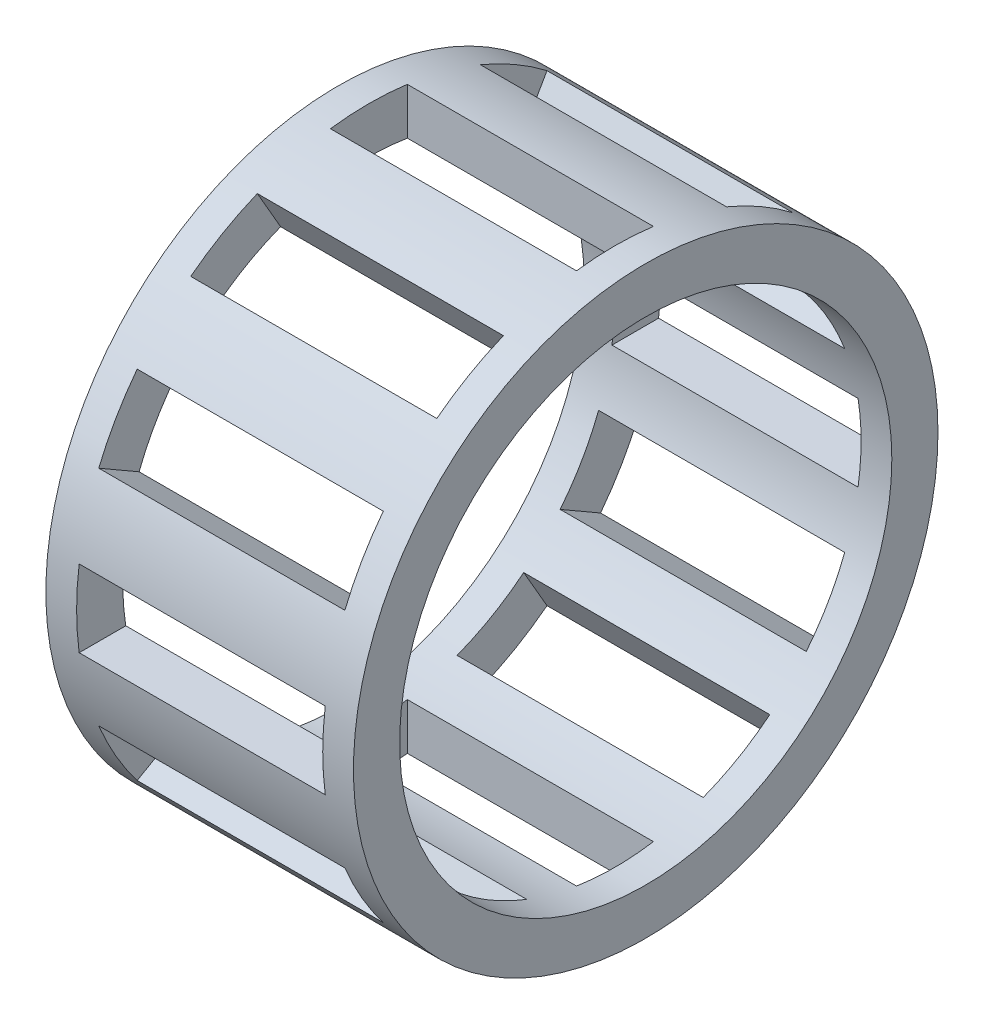
from build123d import *

# Parameters (mm, degrees)
ESQUISSE1_W                  = 10
ESQUISSE1_H                  = 1.5
ESQUISSE2_W                  = 8
ESQUISSE2_H                  = 2.5
ENL_V_MAT_EXTRU_1_DEPTH      = 15.335271187
R_P_TITION_CIRCULAIRE1_COUNT = 12


with BuildPart() as part:
    # Esquisse1 → Base-Révolution (revolve)
    with BuildSketch(Plane.XY):
        with Locations((0, 8.75)):
            Rectangle(ESQUISSE1_W, ESQUISSE1_H)
    revolve(axis=Axis((11.7, 0, 0), (-1, 0, 0)))

    # Esquisse2 → Enlèv. mat.-Extru.1 (cut, through all)
    with BuildSketch(Plane.XY):
        Rectangle(ESQUISSE2_W, ESQUISSE2_H)
    enl_v_mat_extru_1 = extrude(amount=-ENL_V_MAT_EXTRU_1_DEPTH, mode=Mode.SUBTRACT)

    # Répétition circulaire1: Enlèv. mat.-Extru.1 ×12 about axis
    r_p_tition_circulaire1_axis = Axis((-50, 0, 0), (1, 0, 0))
    for i in range(1, R_P_TITION_CIRCULAIRE1_COUNT):
        add(enl_v_mat_extru_1.rotate(r_p_tition_circulaire1_axis, i * 360 / R_P_TITION_CIRCULAIRE1_COUNT), mode=Mode.SUBTRACT)


solid = part.part
